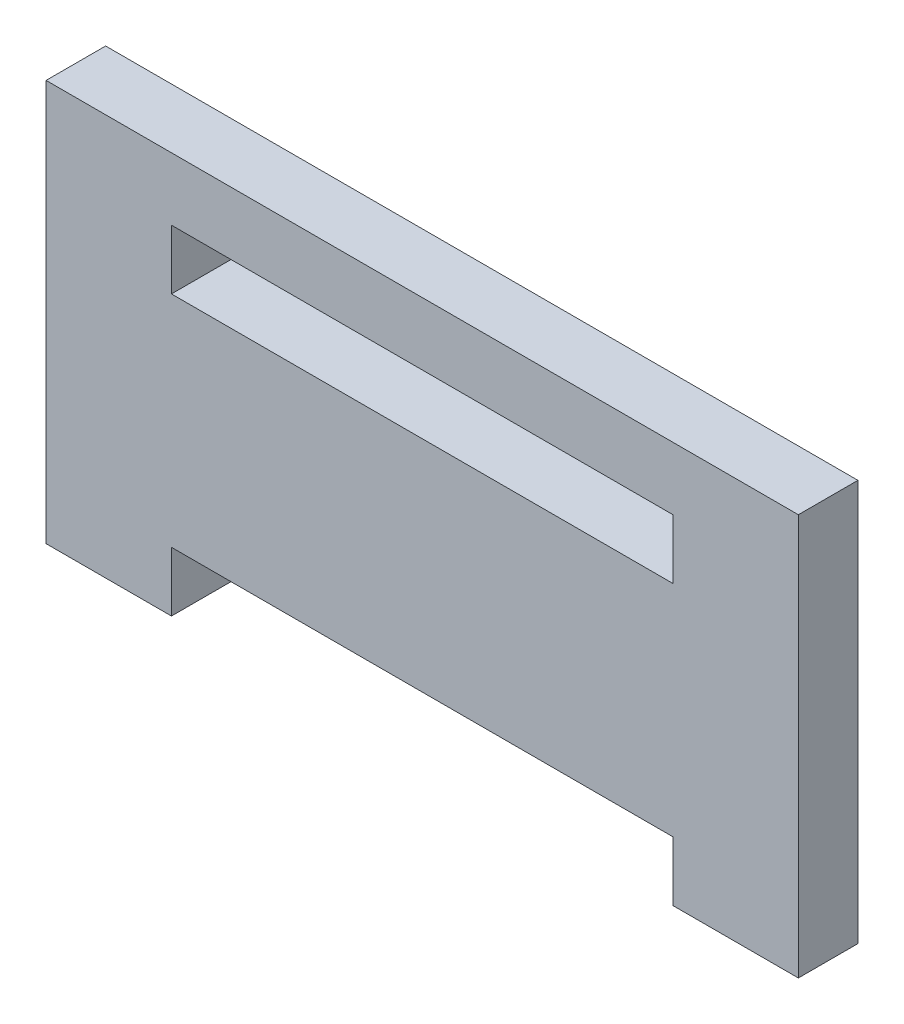
from build123d import *

# Parameters (mm, degrees)
BOSS_EXTRUDE1_DEPTH = 4.75
SKETCH2_W           = 60
SKETCH2_H           = 4.75
BOSS_EXTRUDE2_DEPTH = 5


with BuildPart() as part:
    # Sketch1 → Boss-Extrude1 (new body)
    with BuildSketch(Plane.XY):
        Polygon((0, 0), (10, 0), (10, 4.75), (50, 4.75), (50, 0), (60, 0), (60, 27), (50, 27), (50, 22.25), (10, 22.25), (10, 27), (0, 27), align=None)
    extrude(amount=BOSS_EXTRUDE1_DEPTH)

    # Sketch2 → Boss-Extrude2 (add)
    with BuildSketch(Plane(origin=(0, 27, 0), x_dir=(1, 0, 0), z_dir=(0, 1, 0))):
        with Locations((30, -2.375)):
            Rectangle(SKETCH2_W, SKETCH2_H)
    extrude(amount=BOSS_EXTRUDE2_DEPTH)


solid = part.part
